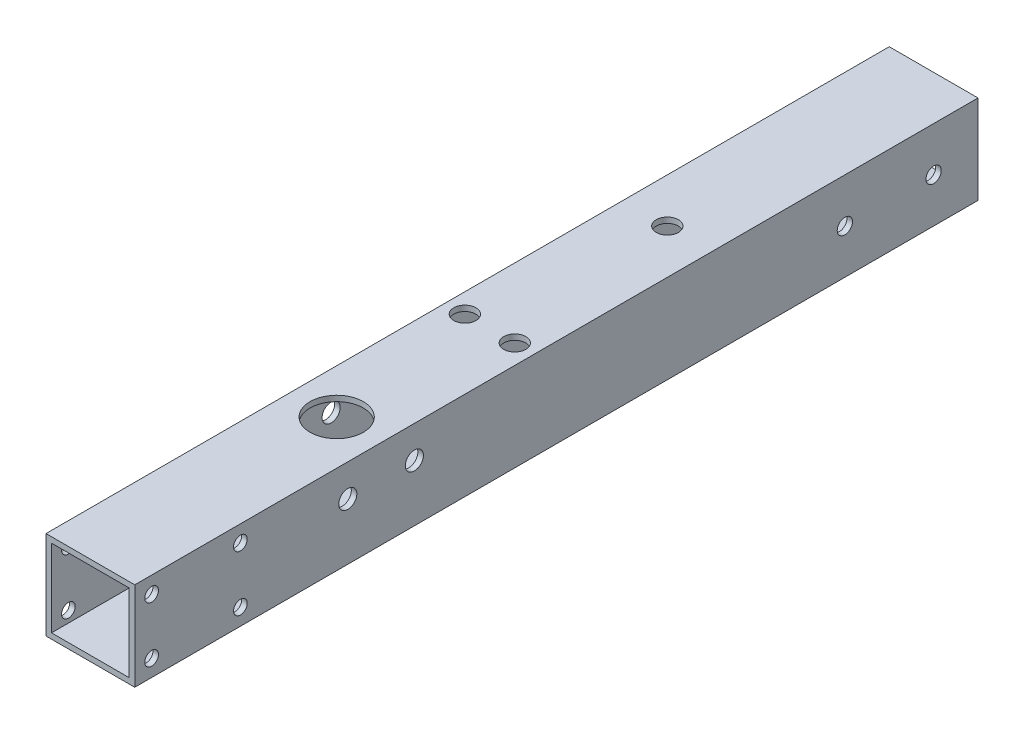
from build123d import *

# Parameters (mm, degrees)
SKETCH1_W           = 25.4
SKETCH1_H           = 25.4
SKETCH1_W_2         = 22.225
SKETCH1_H_2         = 22.225
BOSS_EXTRUDE1_DEPTH = 241.3
SKETCH7_R           = 1.984375
CUT_EXTRUDE8_DEPTH  = 26.4
SKETCH10_R          = 2.1828125
CUT_EXTRUDE7_DEPTH  = 25.4
SKETCH7_5_R         = 3.175
SKETCH7_5_R_2       = 1.984375
CUT_EXTRUDE9_DEPTH  = 1.5875
SKETCH13_R          = 2.5908
CUT_EXTRUDE10_DEPTH = 26.4
CUT_EXTRUDE11_REACH = 27.4
SKETCH14_R          = 7.62
SKETCH16_R          = 1.9558
CUT_EXTRUDE12_DEPTH = 26.4


with BuildPart() as part:
    # Sketch1 → Boss-Extrude1 (new body)
    with BuildSketch(Plane.XY):
        Rectangle(SKETCH1_W, SKETCH1_H)
        Rectangle(SKETCH1_W_2, SKETCH1_H_2, mode=Mode.SUBTRACT)
    extrude(amount=BOSS_EXTRUDE1_DEPTH)

    # Sketch7 → Cut-Extrude8 (cut, through all)
    with BuildSketch(Plane(origin=(0, 12.7, 0), x_dir=(1, 0, 0), z_dir=(0, 1, 0))):
        with Locations((-7.14375, -127)):
            Circle(SKETCH7_R)
        with Locations((7.14375, -127)):
            Circle(SKETCH7_R)
        with Locations((0, -76.2)):
            Circle(SKETCH7_R)
    extrude(amount=-CUT_EXTRUDE8_DEPTH, mode=Mode.SUBTRACT)

    # Sketch10 → Cut-Extrude7 (cut)
    with BuildSketch(Plane.ZY.offset(12.7)):
        with Locations((12.7, 0)):
            Circle(SKETCH10_R)
        with Locations((38.1, 0)):
            Circle(SKETCH10_R)
    extrude(amount=-CUT_EXTRUDE7_DEPTH, mode=Mode.SUBTRACT)

    # Sketch7_5 → Cut-Extrude9 (cut)
    with BuildSketch(Plane(origin=(0, 12.7, 0), x_dir=(1, 0, 0), z_dir=(0, 1, 0))):
        with Locations((-7.14375, -127)):
            Circle(SKETCH7_5_R)
        with Locations((-7.14375, -127)):
            Circle(SKETCH7_5_R_2, mode=Mode.SUBTRACT)
        with Locations((7.14375, -127)):
            Circle(SKETCH7_5_R)
        with Locations((7.14375, -127)):
            Circle(SKETCH7_5_R_2, mode=Mode.SUBTRACT)
        with Locations((0, -76.2)):
            Circle(SKETCH7_5_R)
        with Locations((0, -76.2)):
            Circle(SKETCH7_5_R_2, mode=Mode.SUBTRACT)
    extrude(amount=-CUT_EXTRUDE9_DEPTH, mode=Mode.SUBTRACT)

    # Sketch13 → Cut-Extrude10 (cut, through all)
    with BuildSketch(Plane.ZY.offset(12.7)):
        with Locations((161.29, 3.4925)):
            Circle(SKETCH13_R)
        with Locations((180.34, 3.4925)):
            Circle(SKETCH13_R)
    extrude(amount=-CUT_EXTRUDE10_DEPTH, mode=Mode.SUBTRACT)

    # Sketch14 → Cut-Extrude11 (cut, up to next)
    with BuildSketch(Plane(origin=(0, 12.7, 0), x_dir=(1, 0, 0), z_dir=(0, 1, 0)), mode=Mode.PRIVATE) as cut_extrude11_sk1:
        with Locations((0, -170.815)):
            Circle(SKETCH14_R)
    cut_extrude11_tool1 = extrude(cut_extrude11_sk1.sketch, amount=-CUT_EXTRUDE11_REACH, mode=Mode.PRIVATE) & part.part
    add(cut_extrude11_tool1.solids().sort_by_distance((0, 12.7, 170.815))[0], mode=Mode.SUBTRACT)

    # Sketch16 → Cut-Extrude12 (cut, through all)
    with BuildSketch(Plane(origin=(12.7, 0, 0), x_dir=(0, 0, -1), z_dir=(1, 0, 0))):
        with Locations((-236.474, -7.9375)):
            Circle(SKETCH16_R)
        with Locations((-236.474, 7.9375)):
            Circle(SKETCH16_R)
        with Locations((-211.074, -7.9375)):
            Circle(SKETCH16_R)
        with Locations((-211.074, 7.9375)):
            Circle(SKETCH16_R)
    extrude(amount=-CUT_EXTRUDE12_DEPTH, mode=Mode.SUBTRACT)


solid = part.part
